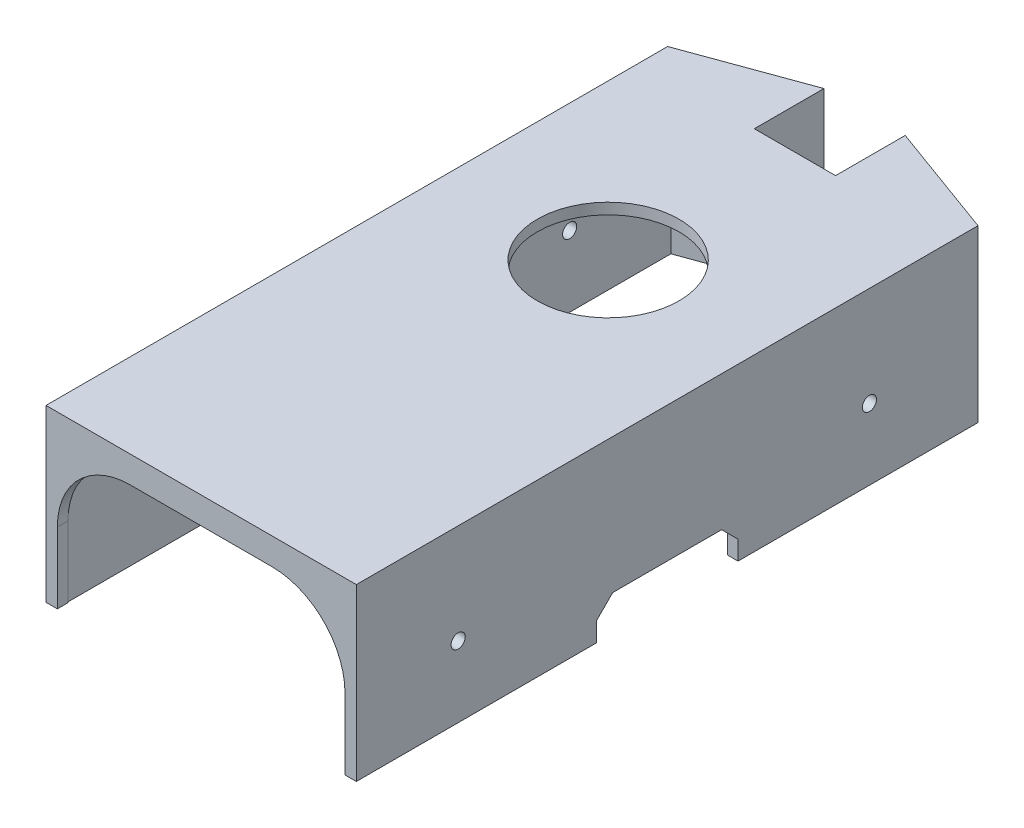
from build123d import *

# Parameters (mm, degrees)
BOSS_EXTRUDE1_DEPTH = 50
BOSS_EXTRUDE2_DEPTH = 1.52
CUT_EXTRUDE2_DEPTH  = 1.52
CUT_EXTRUDE3_DEPTH  = 29
BOSS_EXTRUDE3_DEPTH = 1.55
SKETCH6_R           = 1
CUT_EXTRUDE4_DEPTH  = 77.55
CUT_EXTRUDE5_DEPTH  = 77.55
SKETCH8_R           = 1
CUT_EXTRUDE6_DEPTH  = 70
BOSS_EXTRUDE4_DEPTH = 1.5
BOSS_EXTRUDE5_DEPTH = 1.5
SKETCH12_R          = 10
CUT_EXTRUDE7_DEPTH  = 70


with BuildPart() as part:
    # Sketch1 → Boss-Extrude1 (new body)
    with BuildSketch(Plane(origin=(0, 0, 0), x_dir=(1, 0, 0), z_dir=(0, 1, 0))):
        Polygon((-22.935245878, -45.076760645), (20.864754122, -45.076760645), (20.864754122, 42.660744493), (4.698193973, 48.553690828), (4.698193973, 38.723239355), (-6.768685729, 38.723239355), (-6.768685729, 48.553690828), (-22.935245878, 42.660744493), align=None)
        Polygon((-21.435245878, -43.576760645), (19.364754122, -43.576760645), (19.364754122, 41.610970221), (6.198193973, 46.410372917), (6.198193973, 37.223239355), (-8.268685729, 37.223239355), (-8.268685729, 46.410372917), (-21.435245878, 41.610970221), align=None, mode=Mode.SUBTRACT)
    extrude(amount=BOSS_EXTRUDE1_DEPTH)

    # Sketch2 → Boss-Extrude2 (add)
    with BuildSketch(Plane(origin=(0, 50, 0), x_dir=(1, 0, 0), z_dir=(0, 1, 0))):
        Polygon((-22.935245878, 42.660744493), (-22.935245878, -45.076760645), (20.864754122, -45.076760645), (20.864754122, 42.660744493), (4.698193973, 48.553690828), (4.698193973, 38.723239355), (-6.768685729, 38.723239355), (-6.768685729, 48.553690828), align=None)
    extrude(amount=BOSS_EXTRUDE2_DEPTH)

    # Sketch3 → Cut-Extrude2 (cut)
    with BuildSketch(Plane.XY.offset(45.076760645)):
        with BuildLine():
            ThreePointArc((-11.035245878, 20), (-18.10631369, 17.071067812), (-21.035245878, 10))
            Line((-21.035245878, 10), (-21.035245878, 0))
            Line((-21.035245878, 0), (18.964754122, 0))
            Line((18.964754122, 0), (18.964754122, 10))
            ThreePointArc((18.964754122, 10), (16.035821934, 17.071067812), (8.964754122, 20))
            Line((8.964754122, 20), (-11.035245878, 20))
        make_face()
        with BuildLine():
            Line((-21.035245878, 0), (-21.035245878, 10))
            ThreePointArc((-21.035245878, 10), (-18.10631369, 17.071067812), (-11.035245878, 20))
            Line((-11.035245878, 20), (8.964754122, 20))
            ThreePointArc((8.964754122, 20), (16.035821934, 17.071067812), (18.964754122, 10))
            Line((18.964754122, 10), (18.964754122, 0))
            Line((18.964754122, 0), (19.264754122, 0))
            Line((19.264754122, 0), (19.264754122, 10))
            ThreePointArc((19.264754122, 10), (16.247953968, 17.283199846), (8.964754122, 20.3))
            Line((8.964754122, 20.3), (-11.035245878, 20.3))
            ThreePointArc((-11.035245878, 20.3), (-18.318445724, 17.283199846), (-21.335245878, 10))
            Line((-21.335245878, 10), (-21.335245878, 0))
            Line((-21.335245878, 0), (-21.035245878, 0))
        make_face()
    extrude(amount=-CUT_EXTRUDE2_DEPTH, mode=Mode.SUBTRACT)

    # Sketch4 → Cut-Extrude3 (cut)
    with BuildSketch(Plane(origin=(0, 51.52, 0), x_dir=(1, 0, 0), z_dir=(0, 1, 0))):
        Polygon((-6.768685729, 48.553690828), (-22.935245878, 42.660744493), (-22.935245878, -45.076760645), (20.864754122, -45.076760645), (20.864754122, 42.660744493), (4.698193973, 48.553690828), (4.698193973, 38.723239355), (-6.768685729, 38.723239355), align=None)
    extrude(amount=-CUT_EXTRUDE3_DEPTH, mode=Mode.SUBTRACT)

    # Sketch5 → Boss-Extrude3 (add)
    with BuildSketch(Plane(origin=(0, 22.52, 0), x_dir=(1, 0, 0), z_dir=(0, 1, 0))):
        Polygon((-6.768685729, 38.723239355), (-6.768685729, 48.553690828), (-22.935245878, 42.660744493), (-22.935245878, -45.076760645), (20.864754122, -45.076760645), (20.864754122, 42.660744493), (4.698193973, 48.553690828), (4.698193973, 38.723239355), align=None)
    extrude(amount=BOSS_EXTRUDE3_DEPTH)

    # Sketch6 → Cut-Extrude4 (cut)
    with BuildSketch(Plane(origin=(20.864754122, 0, 0), x_dir=(0, 0, -1), z_dir=(1, 0, 0))):
        with Locations((28.752953433, 10)):
            Circle(SKETCH6_R)
        with Locations((-29.280174862, 10)):
            Circle(SKETCH6_R)
    extrude(amount=-CUT_EXTRUDE4_DEPTH, mode=Mode.SUBTRACT)

    # Sketch7 → Cut-Extrude5 (cut)
    with BuildSketch(Plane(origin=(20.864754122, 0, 0), x_dir=(0, 0, -1), z_dir=(1, 0, 0))):
        Polygon((6.475840318, 5), (-8.89185647, 5), (-11.208008076, 2.683848394), (-11.208008076, 0), (8.791991924, 0), (8.791991924, 2.683848394), align=None)
    extrude(amount=-CUT_EXTRUDE5_DEPTH, mode=Mode.SUBTRACT)

    # Sketch8 → Cut-Extrude6 (cut)
    with BuildSketch(Plane(origin=(20.864754122, 0, 0), x_dir=(0, 0, -1), z_dir=(1, 0, 0))):
        with BuildLine():
            ThreePointArc((28.041256502, 10.702486639), (26.94988664, 10.925120784), (26.32955957, 10))
            Line((26.32955957, 10), (27.752953433, 10))
            ThreePointArc((27.752953433, 10), (27.827832649, 10.379672931), (28.041256502, 10.702486639))
        make_face()
        with BuildLine():
            Line((27.752953433, 10), (26.32955957, 10))
            ThreePointArc((26.32955957, 10), (26.94988664, 9.074879216), (28.041256502, 9.297513361))
            ThreePointArc((28.041256502, 9.297513361), (27.827832649, 9.620327069), (27.752953433, 10))
        make_face()
        with BuildLine():
            ThreePointArc((28.041256502, 10.702486639), (27.827832649, 10.379672931), (27.752953433, 10))
            Line((27.752953433, 10), (28.32955957, 10))
            ThreePointArc((28.32955957, 10), (28.254680355, 10.379672931), (28.041256502, 10.702486639))
        make_face()
        with BuildLine():
            Line((28.32955957, 10), (27.752953433, 10))
            ThreePointArc((27.752953433, 10), (27.827832649, 9.620327069), (28.041256502, 9.297513361))
            ThreePointArc((28.041256502, 9.297513361), (28.254680355, 9.620327069), (28.32955957, 10))
        make_face()
        with BuildLine():
            ThreePointArc((29.752953433, 10), (29.132626364, 10.925120784), (28.041256502, 10.702486639))
            ThreePointArc((28.041256502, 10.702486639), (28.254680355, 10.379672931), (28.32955957, 10))
            ThreePointArc((28.32955957, 10), (28.254680355, 9.620327069), (28.041256502, 9.297513361))
            ThreePointArc((28.041256502, 9.297513361), (29.132626364, 9.074879216), (29.752953433, 10))
        make_face()
        with Locations((-30.703568725, 10)):
            Circle(SKETCH8_R)
        with Locations((-29.280174862, 10)):
            Circle(SKETCH8_R)
    extrude(amount=-CUT_EXTRUDE6_DEPTH, mode=Mode.SUBTRACT)

    # Sketch10 → Boss-Extrude4 (add)
    with BuildSketch(Plane(origin=(20.864754122, 0, 0), x_dir=(0, 0, -1), z_dir=(1, 0, 0))):
        with BuildLine():
            ThreePointArc((-29.991871794, 9.297513361), (-28.280174862, 10), (-29.991871794, 10.702486639))
            ThreePointArc((-29.991871794, 10.702486639), (-29.778447941, 10.379672931), (-29.703568725, 10))
            ThreePointArc((-29.703568725, 10), (-29.778447941, 9.620327069), (-29.991871794, 9.297513361))
        make_face()
        with BuildLine():
            ThreePointArc((28.041256502, 10.702486639), (28.254680355, 10.379672931), (28.32955957, 10))
            ThreePointArc((28.32955957, 10), (28.254680355, 9.620327069), (28.041256502, 9.297513361))
            ThreePointArc((28.041256502, 9.297513361), (29.752953433, 10), (28.041256502, 10.702486639))
        make_face()
    extrude(amount=-BOSS_EXTRUDE4_DEPTH)

    # Sketch11 → Boss-Extrude5 (add)
    with BuildSketch(Plane.ZY.offset(22.935245878)):
        Polygon((-41.610970221, 22.52), (-41.610970221, 0), (-8.791991924, 0), (-8.791991924, 2.683848394), (-6.475840318, 5), (8.89185647, 5), (11.208008076, 2.683848394), (11.208008076, 0), (43.576760645, 0), (43.576760645, 22.52), align=None)
        with BuildLine():
            ThreePointArc((-28.041256502, 10.702486639), (-26.94988664, 10.925120784), (-26.32955957, 10))
            ThreePointArc((-26.32955957, 10), (-26.94988664, 9.074879216), (-28.041256502, 9.297513361))
            ThreePointArc((-28.041256502, 9.297513361), (-29.752953433, 10), (-28.041256502, 10.702486639))
        make_face(mode=Mode.SUBTRACT)
        with BuildLine():
            ThreePointArc((29.991871794, 10.702486639), (31.083241656, 10.925120784), (31.703568725, 10))
            ThreePointArc((31.703568725, 10), (31.083241656, 9.074879216), (29.991871794, 9.297513361))
            ThreePointArc((29.991871794, 9.297513361), (28.280174862, 10), (29.991871794, 10.702486639))
        make_face(mode=Mode.SUBTRACT)
        with BuildLine():
            ThreePointArc((29.991871794, 9.297513361), (29.703568725, 10), (29.991871794, 10.702486639))
            ThreePointArc((29.991871794, 10.702486639), (28.280174862, 10), (29.991871794, 9.297513361))
        make_face()
        with BuildLine():
            ThreePointArc((-28.041256502, 9.297513361), (-28.32955957, 10), (-28.041256502, 10.702486639))
            ThreePointArc((-28.041256502, 10.702486639), (-29.752953433, 10), (-28.041256502, 9.297513361))
        make_face()
    extrude(amount=-BOSS_EXTRUDE5_DEPTH)

    # Sketch12 → Cut-Extrude7 (cut)
    with BuildSketch(Plane(origin=(0, 24.07, 0), x_dir=(1, 0, 0), z_dir=(0, 1, 0))):
        with Locations(Location((-1.035245878, 12.363239355, 0), (0, 0, 270))):
            Circle(SKETCH12_R)
    extrude(amount=-CUT_EXTRUDE7_DEPTH, mode=Mode.SUBTRACT)


solid = part.part
